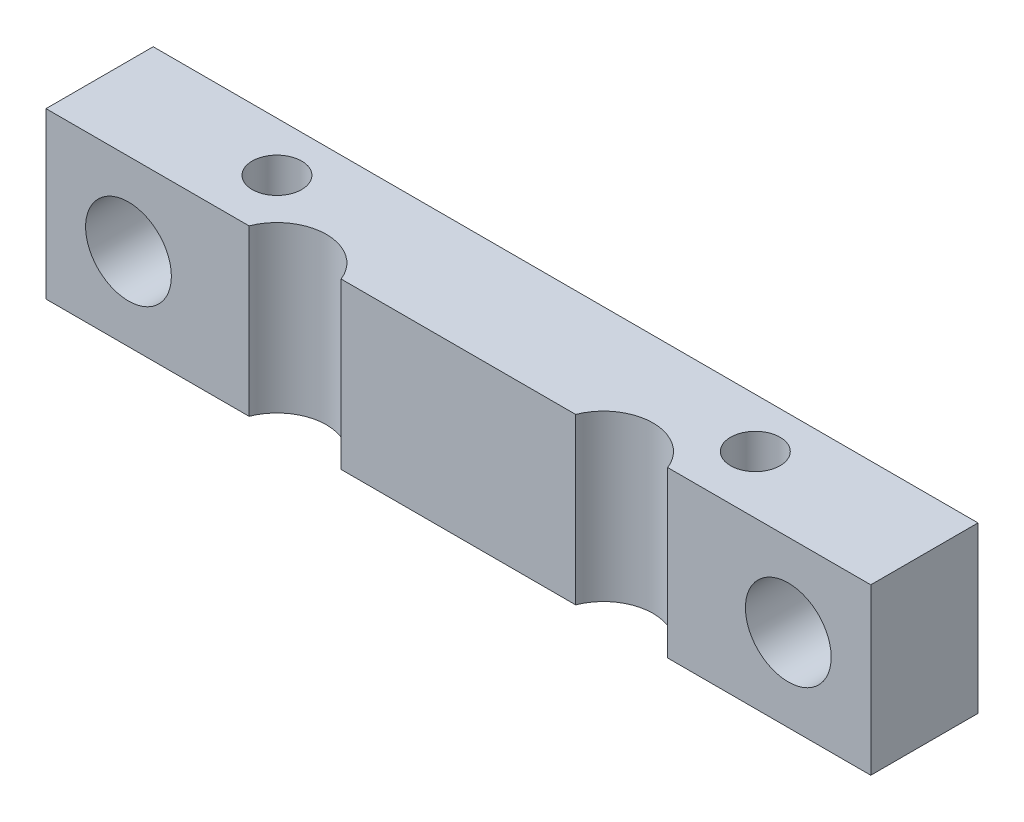
from build123d import *

# Parameters (mm, degrees)
SKETCH1_R           = 1.5
BOSS_EXTRUDE1_DEPTH = 10
CUT_EXTRUDE1_REACH  = 8.5
SKETCH2_R           = 2.6


with BuildPart() as part:
    # Sketch1 → Boss-Extrude1 (new body)
    with BuildSketch(Plane(origin=(0, 0, 0), x_dir=(1, 0, 0), z_dir=(0, 1, 0))):
        with BuildLine():
            Line((0, 0), (12.309647022, 0))
            ThreePointArc((12.309647022, 0), (15.100505063, 1.899494937), (17.891363104, 0))
            Line((17.891363104, 0), (32.108636896, 0))
            ThreePointArc((32.108636896, 0), (34.899494937, 1.899494937), (37.690352978, 0))
            Line((37.690352978, 0), (50, 0))
            Line((50, 0), (50, 6.5))
            Line((50, 6.5), (0, 6.5))
            Line((0, 6.5), (0, 0))
        make_face()
        with Locations((10.5, 3.5)):
            Circle(SKETCH1_R, mode=Mode.SUBTRACT)
        with Locations((39.5, 3.5)):
            Circle(SKETCH1_R, mode=Mode.SUBTRACT)
    extrude(amount=BOSS_EXTRUDE1_DEPTH)

    # Sketch2 → Cut-Extrude1 (cut, up to next)
    with BuildSketch(Plane.XY, mode=Mode.PRIVATE) as cut_extrude1_sk1:
        with Locations((5, 5)):
            Circle(SKETCH2_R)
    cut_extrude1_tool1 = extrude(cut_extrude1_sk1.sketch, amount=-CUT_EXTRUDE1_REACH, mode=Mode.PRIVATE) & part.part
    add(cut_extrude1_tool1.solids().sort_by_distance((5, 5, 0))[0], mode=Mode.SUBTRACT)
    # Sketch2 → Cut-Extrude1 (cut, up to next)
    with BuildSketch(Plane.XY, mode=Mode.PRIVATE) as cut_extrude1_sk2:
        with Locations((45, 5)):
            Circle(SKETCH2_R)
    cut_extrude1_tool2 = extrude(cut_extrude1_sk2.sketch, amount=-CUT_EXTRUDE1_REACH, mode=Mode.PRIVATE) & part.part
    add(cut_extrude1_tool2.solids().sort_by_distance((45, 5, 0))[0], mode=Mode.SUBTRACT)


solid = part.part
